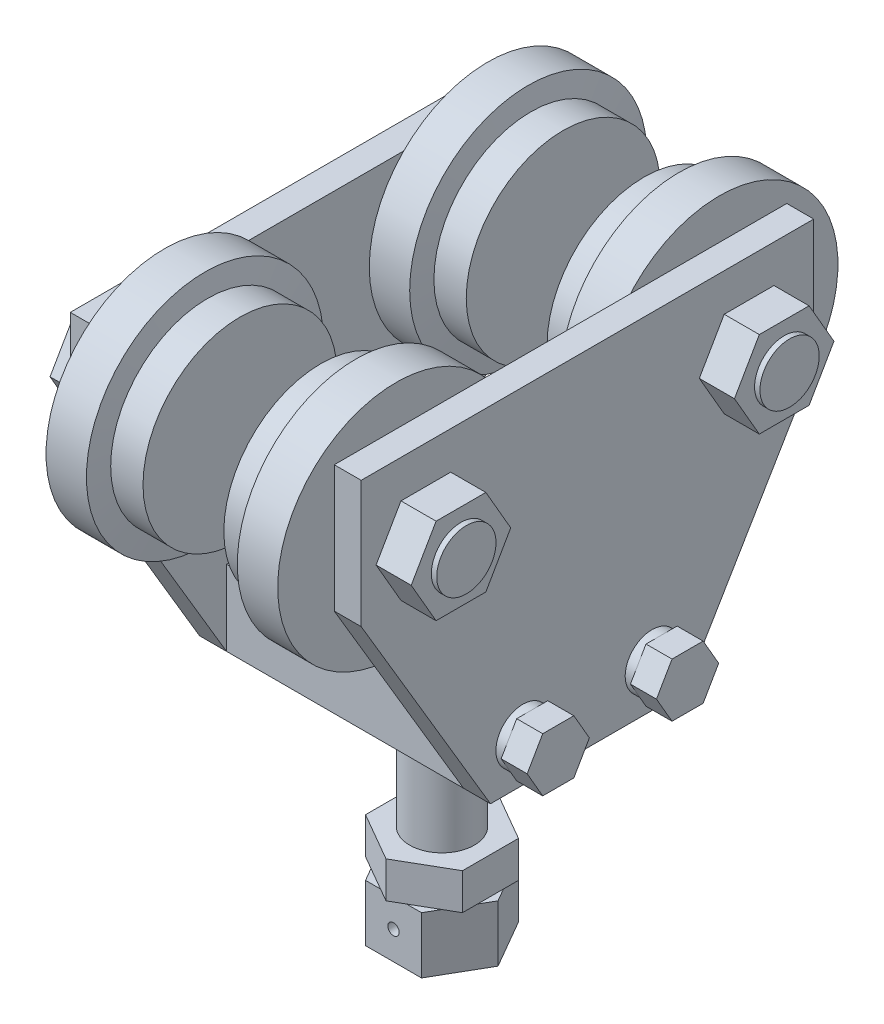
from build123d import *

# Parameters (mm, degrees)
YOKE_CROSS_SECTION_W           = 114.3
YOKE_CROSS_SECTION_H           = 44.45
YOKE_DEPTH                     = 69.85
SIDEPLATE_DEPTH                = 15.875
WHEEL_PIN_NUT_DEPTH            = 20.701
WHEEL_PIN_PROJECTION_PROFILE_R = 17.4625
WHEEL_PIN_PROJECTION_DEPTH     = 3.175
LOCKNUTS_PROFILE_R             = 15.875
LOCKNUTS_DEPTH                 = 5.5626
SCREWS_DEPTH                   = 15.3416
PROFILE_R                      = 28.575
KING_BOLT_HEAD_DEPTH           = 31.75
DIA_R                          = 19.05
KING_BOLT_DEPTH                = 83.052101
KING_BOLT_JAM_NUT_DEPTH        = 21.43125
KING_BOLT_NUT_DEPTH            = 33.3375
SKETCH5_R                      = 19.05
EXTENDED_KING_BOLT_DEPTH       = 6.35
CHAMFER1_SIZE                  = 2.38125
COTTER_PIN_HOLE_REACH          = 163.925
SKETCH11_R                     = 3.3401


with BuildPart() as part:
    # YOKE CROSS SECTION → YOKE (new body)
    with BuildSketch(Plane(origin=(0, 0, 0), x_dir=(0, 0, -1), z_dir=(1, 0, 0))):
        with Locations((0, 22.225)):
            Rectangle(YOKE_CROSS_SECTION_W, YOKE_CROSS_SECTION_H)
    extrude(amount=YOKE_DEPTH)

    # SIDEPLATE PROFILE → SIDEPLATE (add)
    with BuildSketch(Plane(origin=(69.85, 0, 0), x_dir=(0, 0, -1), z_dir=(1, 0, 0))):
        Polygon((-133.35, 203.2), (-133.35, 128.517771554), (-57.15, 0), (0, 0), (57.15, 0), (133.35, 128.517771554), (133.35, 203.2), align=None)
    extrude(amount=SIDEPLATE_DEPTH)

    # WHEEL PIN NUT PROFILE → WHEEL PIN NUT (add)
    with BuildSketch(Plane(origin=(85.725, 0, 0), x_dir=(0, 0, -1), z_dir=(1, 0, 0))):
        Polygon((-65.920606325, 155.575), (-80.585303163, 180.975), (-109.914696837, 180.975), (-124.579393675, 155.575), (-109.914696837, 130.175), (-80.585303163, 130.175), align=None)
    wheel_pin_nut = extrude(amount=WHEEL_PIN_NUT_DEPTH)

    # WHEEL PIN PROJECTION PROFILE → WHEEL PIN PROJECTION (add)
    with BuildSketch(Plane(origin=(106.426, 0, 0), x_dir=(0, 0, -1), z_dir=(1, 0, 0))):
        with Locations((-95.25, 155.575)):
            Circle(WHEEL_PIN_PROJECTION_PROFILE_R)
    wheel_pin_projection = extrude(amount=WHEEL_PIN_PROJECTION_DEPTH)

    # LOCKNUTS PROFILE → LOCKNUTS (add)
    with BuildSketch(Plane(origin=(85.725, 0, 0), x_dir=(0, 0, -1), z_dir=(1, 0, 0))):
        with Locations(Location((-38.1, 25.4, 0), (0, 0, 180))):  # turned: the seam where the file's is
            Circle(LOCKNUTS_PROFILE_R)
    locknuts = extrude(amount=LOCKNUTS_DEPTH)

    # SCREWS PROFILE → SCREWS (add)
    with BuildSketch(Plane(origin=(91.2876, 0, 0), x_dir=(0, 0, -1), z_dir=(1, 0, 0))):
        Polygon((-19.769128953, 25.4), (-28.934564477, 41.275), (-47.265435523, 41.275), (-56.430871047, 25.4), (-47.265435523, 9.525), (-28.934564477, 9.525), align=None)
    screws = extrude(amount=SCREWS_DEPTH)

    # PROFILE → KING BOLT HEAD (add)
    with BuildSketch(Plane(origin=(0, 44.45, 0), x_dir=(-1, 0, 0), z_dir=(0, 1, 0))):
        with Locations(Location((0, 0, 0), (0, 0, 90))):  # turned: the seam where the file's is
            Circle(PROFILE_R)
    extrude(amount=KING_BOLT_HEAD_DEPTH)

    # Mirror1: WHEEL PIN NUT, WHEEL PIN PROJECTION across plane
    add(wheel_pin_nut.mirror(Plane.XY))
    add(wheel_pin_projection.mirror(Plane.XY))

    # Mirror YOKE SCREWS: LOCKNUTS, SCREWS across plane
    add(locknuts.mirror(Plane.XY))
    add(screws.mirror(Plane.XY))

    # Mirror SIDE 1: part across plane


with BuildPart() as part_1:
    add(part.part)
    add(part.part.mirror(Plane(origin=(0, 0, 0), x_dir=(0, 0, 1), z_dir=(1, 0, 0))))

    # DIA. → KING BOLT (add)
    with BuildSketch(Plane.XZ):
        with Locations(Location((0, 0, 0), (0, 0, 90))):  # turned: the seam where the file's is
            Circle(DIA_R)
    extrude(amount=KING_BOLT_DEPTH)

    # KING BOLT JAN NUT PROFILE → KING BOLT JAM NUT (add)
    with BuildSketch(Plane.XZ.offset(83.052100888)):
        Polygon((0, -32.995567884), (28.575, -16.497783942), (28.575, 16.497783942), (0, 32.995567884), (-28.575, 16.497783942), (-28.575, -16.497783942), align=None)
    extrude(amount=KING_BOLT_JAM_NUT_DEPTH)

    # KING BOLT NUT PROFILE → KING BOLT NUT (add)
    with BuildSketch(Plane.XZ.offset(104.483350888)):
        Polygon((32.995567884, 0), (16.497783942, 28.575), (-16.497783942, 28.575), (-32.995567884, 0), (-16.497783942, -28.575), (16.497783942, -28.575), align=None)
    extrude(amount=KING_BOLT_NUT_DEPTH)

    # Sketch5 → EXTENDED KING BOLT (add)
    with BuildSketch(Plane.XZ.offset(137.820850888)):
        with Locations(Location((0, 0, 0), (0, 0, 90))):  # turned: the seam where the file's is
            Circle(SKETCH5_R)
    extrude(amount=EXTENDED_KING_BOLT_DEPTH)

    # Chamfer1
    chamfer1_edges = [part_1.edges().sort_by_distance(p)[0] for p in [
        (0, -144.170850888, -19.05),
    ]]
    chamfer(chamfer1_edges, length=CHAMFER1_SIZE)

    # Sketch11 → COTTER PIN HOLE (cut, up to next)
    with BuildSketch(Plane(origin=(0, 0, -28.575), x_dir=(-1, 0, 0), z_dir=(0, 0, -1)), mode=Mode.PRIVATE) as cotter_pin_hole_sk1:
        with Locations((0, -121.152100888)):
            Circle(SKETCH11_R)
    cotter_pin_hole_tool1 = extrude(cotter_pin_hole_sk1.sketch, amount=-COTTER_PIN_HOLE_REACH, mode=Mode.PRIVATE) & part_1.part
    add(cotter_pin_hole_tool1.solids().sort_by_distance((0, -121.152101, -28.575))[0], mode=Mode.SUBTRACT)

    # Sketch12 → WHEEL (revolve)
    with BuildSketch(Plane.XY.offset(95.25), mode=Mode.PRIVATE) as wheel_sk:
        Polygon((23.8125, 155.575), (23.8125, 212.725), (42.8625, 212.725), (44.45, 225.425), (68.2625, 225.425), (68.2625, 179.3875), (69.85, 179.3875), (69.85, 155.575), align=None)
    wheel = revolve(wheel_sk.sketch.rotate(Axis((109.601, 155.575, 95.25), (-1, 0, 0)), 90), axis=Axis((109.601, 155.575, 95.25), (-1, 0, 0)))  # turned: the seam where the file's is

    # Mirror2: WHEEL across plane
    add(wheel.mirror(Plane.XY))

    # Mirror3: WHEEL across plane
    add(wheel.mirror(Plane(origin=(0, 0, 0), x_dir=(0, 0, 1), z_dir=(1, 0, 0))))

    # Mirror3 copy 1 sketch → Mirror3 copy 1 (revolve)
    with BuildSketch(Plane(origin=(0, 0, -95.25), x_dir=(-1, 0, 0), z_dir=(0, 0, -1))):
        Polygon((23.8125, 155.575), (23.8125, 212.725), (42.8625, 212.725), (44.45, 225.425), (68.2625, 225.425), (68.2625, 179.3875), (69.85, 179.3875), (69.85, 155.575), align=None)
    revolve(axis=Axis((-109.601, 155.575, -95.25), (1, 0, 0)))


solid = part_1.part
